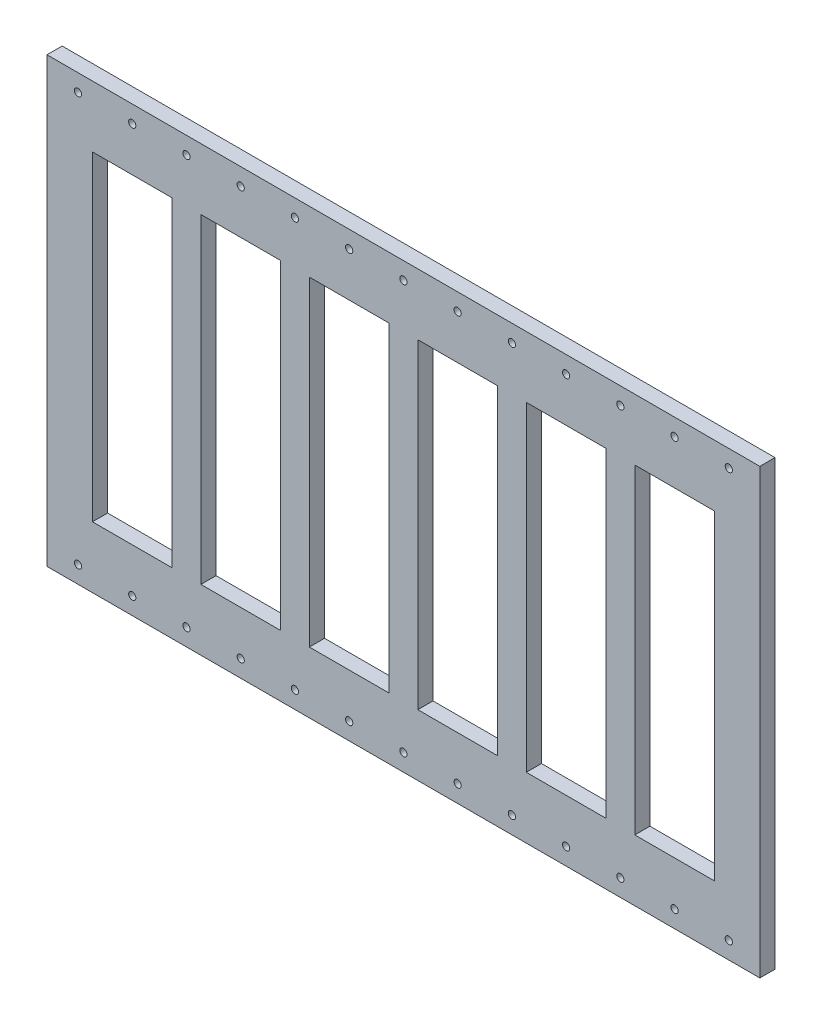
from build123d import *

# Parameters (mm, degrees)
SKETCH1_W           = 469.9
SKETCH1_H           = 292.094
SKETCH1_R           = 2.38125
SKETCH1_W_2         = 52.5
SKETCH1_H_2         = 211.186
BOSS_EXTRUDE1_DEPTH = 10


with BuildPart() as part:
    # Sketch1 → Boss-Extrude1 (new body)
    with BuildSketch(Plane.XY):
        with Locations((213, 105.593)):
            Rectangle(SKETCH1_W, SKETCH1_H)
        with Locations((34.25, -29.180453277)):
            Circle(SKETCH1_R, mode=Mode.SUBTRACT)
        with Locations((70, -29.180453277)):
            Circle(SKETCH1_R, mode=Mode.SUBTRACT)
        with Locations((105.75, -29.180453277)):
            Circle(SKETCH1_R, mode=Mode.SUBTRACT)
        with Locations((141.5, -29.180453277)):
            Circle(SKETCH1_R, mode=Mode.SUBTRACT)
        with Locations((177.25, -29.180453277)):
            Circle(SKETCH1_R, mode=Mode.SUBTRACT)
        with Locations((213, -29.180453277)):
            Circle(SKETCH1_R, mode=Mode.SUBTRACT)
        with Locations((248.75, -29.180453277)):
            Circle(SKETCH1_R, mode=Mode.SUBTRACT)
        with Locations((284.5, -29.180453277)):
            Circle(SKETCH1_R, mode=Mode.SUBTRACT)
        with Locations((320.25, -29.180453277)):
            Circle(SKETCH1_R, mode=Mode.SUBTRACT)
        with Locations((356, -29.180453277)):
            Circle(SKETCH1_R, mode=Mode.SUBTRACT)
        with Locations((391.75, -29.180453277)):
            Circle(SKETCH1_R, mode=Mode.SUBTRACT)
        with Locations((427.5, -29.180453277)):
            Circle(SKETCH1_R, mode=Mode.SUBTRACT)
        with Locations((-1.5, 240.366453277)):
            Circle(SKETCH1_R, mode=Mode.SUBTRACT)
        with Locations((34.25, 240.366453277)):
            Circle(SKETCH1_R, mode=Mode.SUBTRACT)
        with Locations((70, 240.366453277)):
            Circle(SKETCH1_R, mode=Mode.SUBTRACT)
        with Locations((105.75, 240.366453277)):
            Circle(SKETCH1_R, mode=Mode.SUBTRACT)
        with Locations((141.5, 240.366453277)):
            Circle(SKETCH1_R, mode=Mode.SUBTRACT)
        with Locations((177.25, 240.366453277)):
            Circle(SKETCH1_R, mode=Mode.SUBTRACT)
        with Locations((213, 240.366453277)):
            Circle(SKETCH1_R, mode=Mode.SUBTRACT)
        with Locations((-1.5, -29.180453277)):
            Circle(SKETCH1_R, mode=Mode.SUBTRACT)
        with Locations((248.75, 240.366453277)):
            Circle(SKETCH1_R, mode=Mode.SUBTRACT)
        with Locations((284.5, 240.366453277)):
            Circle(SKETCH1_R, mode=Mode.SUBTRACT)
        with Locations((320.25, 240.366453277)):
            Circle(SKETCH1_R, mode=Mode.SUBTRACT)
        with Locations((356, 240.366453277)):
            Circle(SKETCH1_R, mode=Mode.SUBTRACT)
        with Locations((391.75, 240.366453277)):
            Circle(SKETCH1_R, mode=Mode.SUBTRACT)
        with Locations((427.5, 240.366453277)):
            Circle(SKETCH1_R, mode=Mode.SUBTRACT)
        with Locations((34.25, 105.593)):
            Rectangle(SKETCH1_W_2, SKETCH1_H_2, mode=Mode.SUBTRACT)
        with Locations((105.75, 105.593)):
            Rectangle(SKETCH1_W_2, SKETCH1_H_2, mode=Mode.SUBTRACT)
        with Locations((177.25, 105.593)):
            Rectangle(SKETCH1_W_2, SKETCH1_H_2, mode=Mode.SUBTRACT)
        with Locations((248.75, 105.593)):
            Rectangle(SKETCH1_W_2, SKETCH1_H_2, mode=Mode.SUBTRACT)
        with Locations((320.25, 105.593)):
            Rectangle(SKETCH1_W_2, SKETCH1_H_2, mode=Mode.SUBTRACT)
        with Locations((391.75, 105.593)):
            Rectangle(SKETCH1_W_2, SKETCH1_H_2, mode=Mode.SUBTRACT)
    extrude(amount=BOSS_EXTRUDE1_DEPTH)


solid = part.part
